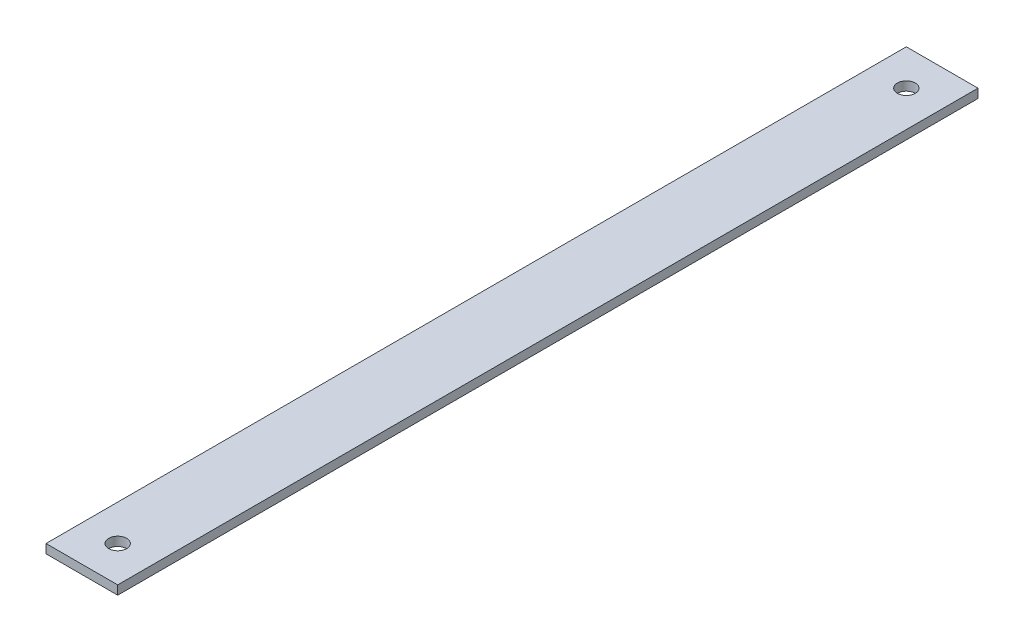
from build123d import *

# Parameters (mm, degrees)
SKETCH1_W           = 50.8
SKETCH1_H           = 609.6
BOSS_EXTRUDE1_DEPTH = 6.35
SKETCH2_R           = 6.35
CUT_EXTRUDE1_DEPTH  = 7.35


with BuildPart() as part:
    # Sketch1 → Boss-Extrude1 (new body)
    with BuildSketch(Plane(origin=(0, 0, 0), x_dir=(1, 0, 0), z_dir=(0, 1, 0))):
        Rectangle(SKETCH1_W, SKETCH1_H)
    extrude(amount=BOSS_EXTRUDE1_DEPTH)

    # Sketch2 → Cut-Extrude1 (cut, through all)
    with BuildSketch(Plane(origin=(0, 6.35, 0), x_dir=(1, 0, 0), z_dir=(0, 1, 0))):
        with Locations((0, 279.4)):
            Circle(SKETCH2_R)
        with Locations((0, -279.4)):
            Circle(SKETCH2_R)
    extrude(amount=-CUT_EXTRUDE1_DEPTH, mode=Mode.SUBTRACT)


solid = part.part
